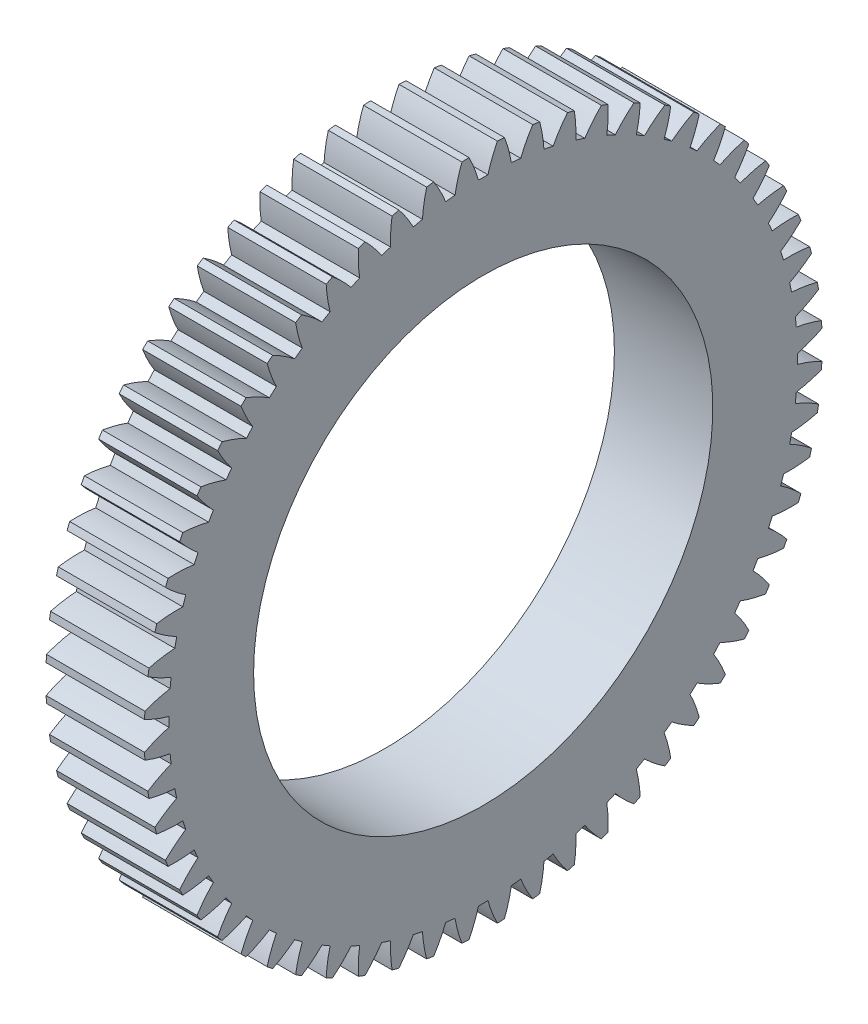
from build123d import *

# Parameters (mm, degrees)
BASPROSKE_W     = 9
BASPROSKE_H     = 31
TOOTHCUT_DEPTH  = 45.754888001
TEETHCUTS_COUNT = 60
TEETHCUTS_ANGLE = 354
BORSKE_R        = 21
BORE_DEPTH      = 50.0000508


with BuildPart() as part:
    # BasProSke → Base-Revolve (revolve)
    with BuildSketch(Plane(origin=(0, 0, 0), x_dir=(1, 0, 0), z_dir=(0, 1, 0)), mode=Mode.PRIVATE) as base_revolve_sk:
        with Locations((4.5, 15.5)):
            Rectangle(BASPROSKE_W, BASPROSKE_H)
    revolve(base_revolve_sk.sketch.rotate(Axis((-10, 0, 0), (1, 0, 0)), 180), axis=Axis((-10, 0, 0), (1, 0, 0)))

    # TooCutSke → ToothCut (cut, through all)
    with BuildSketch(Plane(origin=(0, 0, 0), x_dir=(0, 0, -1), z_dir=(1, 0, 0))):
        with BuildLine():
            ThreePointArc((0.430151971, 28.745781782), (0, 28.749), (-0.430151971, 28.745781782))
            ThreePointArc((-0.430151971, 28.745781782), (-0.81454129, 29.893990802), (-1.312684569, 30.997617721))
            ThreePointArc((-1.312684569, 30.997617721), (0, 31.0254), (1.312684569, 30.997617721))
            ThreePointArc((1.312684569, 30.997617721), (0.81454129, 29.893990802), (0.430151971, 28.745781782))
        make_face()
    toothcut = extrude(amount=TOOTHCUT_DEPTH, mode=Mode.SUBTRACT)

    # TeethCuts: ToothCut ×60 about axis
    teethcuts_axis = Axis((-10, 0, 0), (1, 0, 0))
    for i in range(1, TEETHCUTS_COUNT):
        add(toothcut.rotate(teethcuts_axis, i * TEETHCUTS_ANGLE / (TEETHCUTS_COUNT - 1)), mode=Mode.SUBTRACT)

    # BorSke → Bore (cut, symmetric)
    with BuildSketch(Plane(origin=(0, 0, 0), x_dir=(0, 0, -1), z_dir=(1, 0, 0))):
        with Locations(Location((0, 0, 0), (0, 0, 180))):
            Circle(BORSKE_R)
    extrude(amount=BORE_DEPTH, both=True, mode=Mode.SUBTRACT)


solid = part.part
